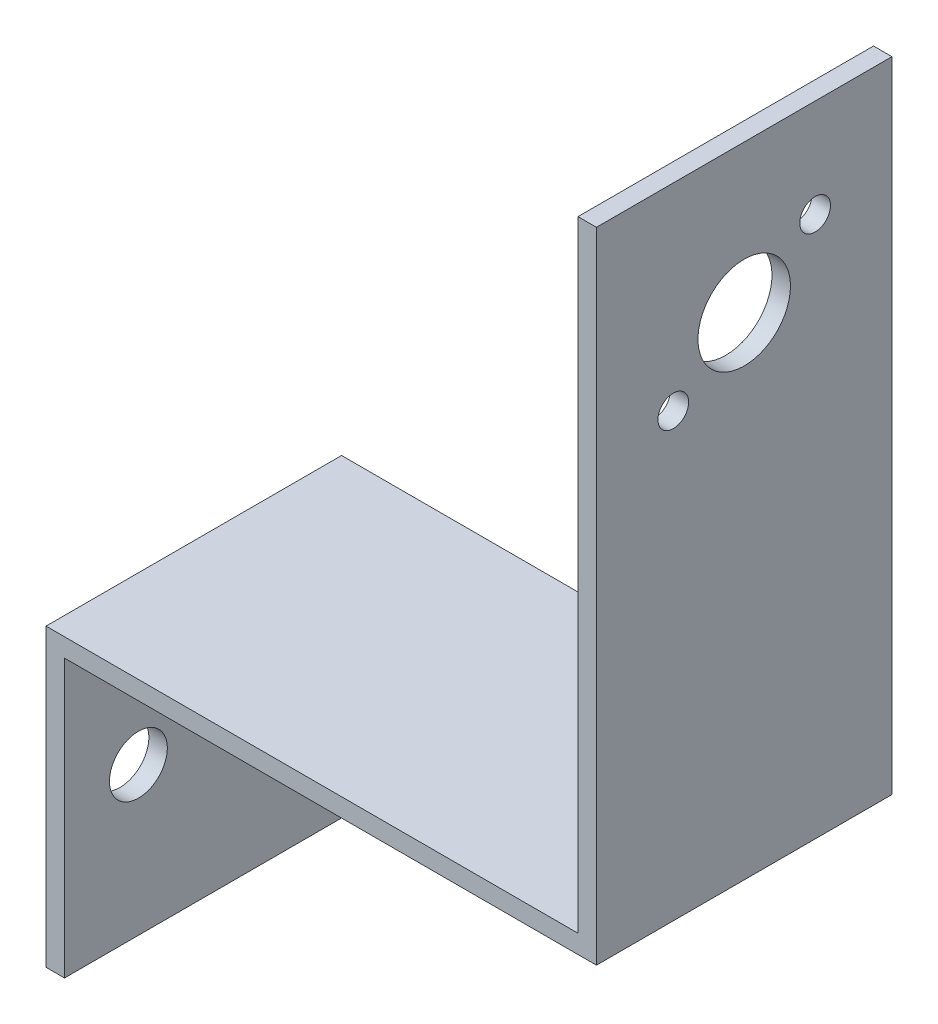
from build123d import *

# Parameters (mm, degrees)
EXTRUDE_THIN1_DEPTH = 25.4
SKETCH2_R           = 3.9751
SKETCH2_R_2         = 1.3208
CUT_EXTRUDE1_DEPTH  = 48.307499936
SKETCH3_R           = 2.4892
CUT_EXTRUDE2_DEPTH  = 2.5875


with BuildPart() as part:
    # Sketch1 → Extrude-Thin1 (new body)
    with BuildSketch(Plane.XY):
        Polygon((0, 0), (0, 25.4), (45.719999936, 25.4), (45.719999936, 78.74), (47.307499936, 78.74), (47.307499936, 23.8125), (1.5875, 23.8125), (1.5875, 0), align=None)
    extrude(amount=EXTRUDE_THIN1_DEPTH)

    # Sketch2 → Cut-Extrude1 (cut, through all)
    with BuildSketch(Plane(origin=(47.307499936, 0, 0), x_dir=(0, 0, -1), z_dir=(1, 0, 0))):
        with Locations((-12.7, 66.04)):
            Circle(SKETCH2_R)
        with Locations((-18.796293344, 61.771329445)):
            Circle(SKETCH2_R_2)
        with Locations((-6.603706656, 70.308670555)):
            Circle(SKETCH2_R_2)
    extrude(amount=-CUT_EXTRUDE1_DEPTH, mode=Mode.SUBTRACT)

    # Sketch3 → Cut-Extrude2 (cut, through all)
    with BuildSketch(Plane(origin=(1.5875, 0, 0), x_dir=(0, 0, -1), z_dir=(1, 0, 0))):
        with Locations((-19.05, 12.7)):
            Circle(SKETCH3_R)
        with Locations((-6.35, 12.7)):
            Circle(SKETCH3_R)
    extrude(amount=-CUT_EXTRUDE2_DEPTH, mode=Mode.SUBTRACT)


solid = part.part
